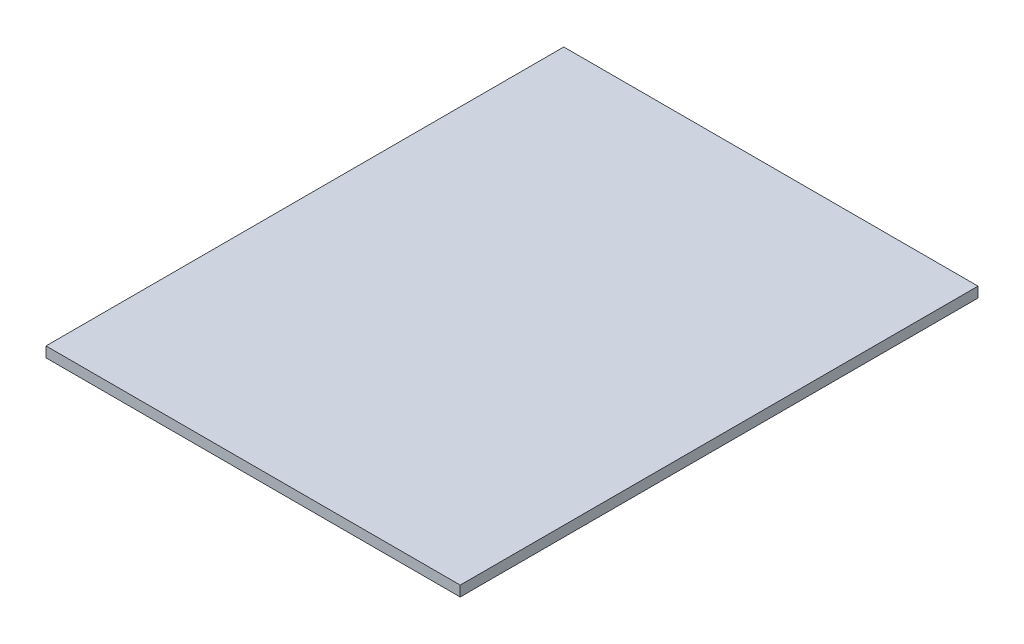
from build123d import *

# Parameters (mm, degrees)
SKETCH1_W           = 200
SKETCH1_H           = 250
BOSS_EXTRUDE1_DEPTH = 5


with BuildPart() as part:
    # Sketch1 → Boss-Extrude1 (new body)
    with BuildSketch(Plane(origin=(0, 0, 0), x_dir=(1, 0, 0), z_dir=(0, 1, 0))):
        with Locations((10402.442645447, -3483.547869862)):
            Rectangle(SKETCH1_W, SKETCH1_H)
    extrude(amount=BOSS_EXTRUDE1_DEPTH)


solid = part.part
